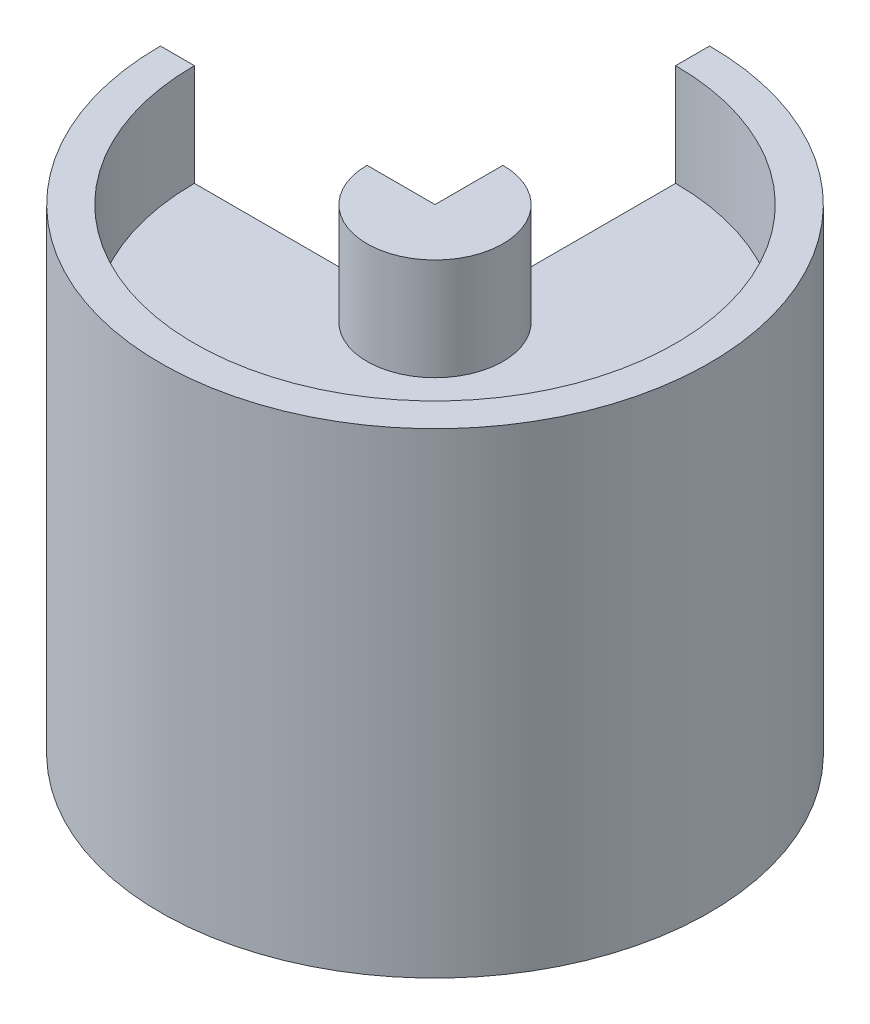
from build123d import *

# Parameters (mm, degrees)
REVOLVE2_ANGLE      = 270
BOSS_EXTRUDE1_DEPTH = 44.45


with BuildPart() as part:
    # Sketch1 → Revolve2 (revolve)
    with BuildSketch(Plane(origin=(0, 0, 0), x_dir=(0, 0, -1), z_dir=(1, 0, 0))):
        Polygon((22.479, 35.498434974), (22.479, 45.023434974), (25.654, 45.023434974), (25.654, 0.573434974), (22.479, 0.573434974), (22.479, 32.323434974), (6.35, 32.323434974), (6.35, 0.573434974), (3.175, 0.573434974), (3.175, 45.023434974), (6.35, 45.023434974), (6.35, 35.498434974), align=None)
    revolve(axis=Axis((0, 45.023434974, 0), (0, -1, 0)), revolution_arc=REVOLVE2_ANGLE)

    # Sketch2 → Boss-Extrude1 (add, through all)
    with BuildSketch(Plane(origin=(0, 45.023434974, 0), x_dir=(1, 0, 0), z_dir=(0, 1, 0))):
        with BuildLine():
            Line((0, 6.35), (0, 3.175))
            Line((0, 3.175), (0, 0))
            Line((0, 0), (-3.175, 0))
            Line((-3.175, 0), (-6.35, 0))
            ThreePointArc((-6.35, 0), (4.490128061, -4.490128061), (0, 6.35))
        make_face()
    extrude(amount=-BOSS_EXTRUDE1_DEPTH)


solid = part.part
